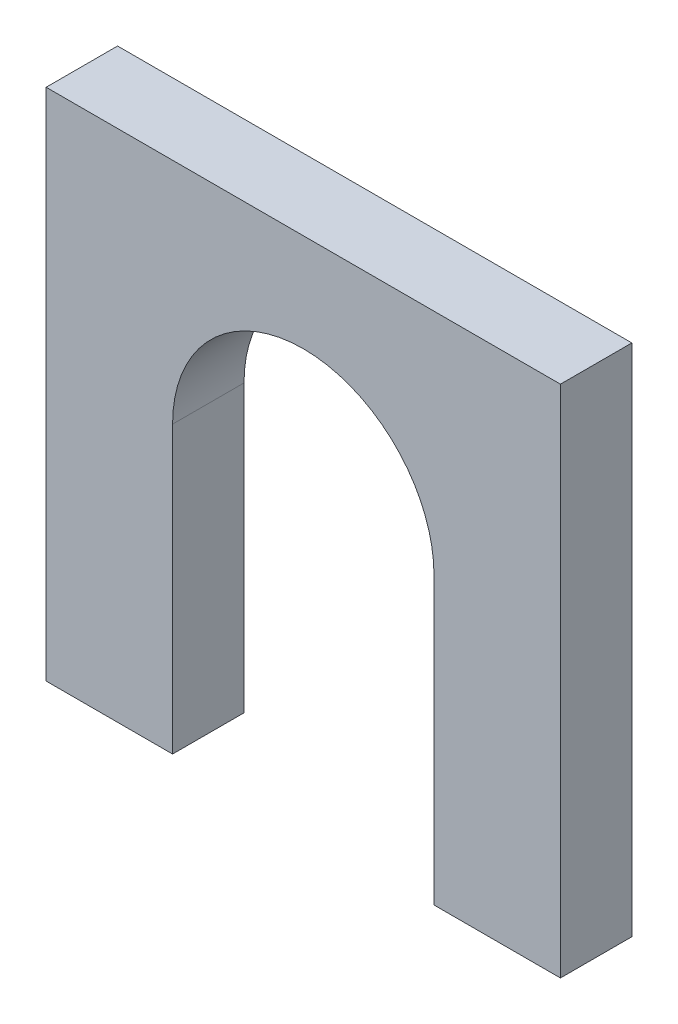
from build123d import *

# Parameters (mm, degrees)
BOSS_EXTRUDE1_DEPTH = 6.35


with BuildPart() as part:
    # Sketch1 → Boss-Extrude1 (new body)
    with BuildSketch(Plane.XY):
        with BuildLine():
            Line((34.4805, 0), (45.72, 0))
            Line((45.72, 0), (45.72, 45.72))
            Line((45.72, 45.72), (0, 45.72))
            Line((0, 45.72), (0, 0))
            Line((0, 0), (11.2395, 0))
            Line((11.2395, 0), (11.2395, 25.4))
            ThreePointArc((11.2395, 25.4), (22.86, 37.0205), (34.4805, 25.4))
            Line((34.4805, 25.4), (34.4805, 0))
        make_face()
    extrude(amount=BOSS_EXTRUDE1_DEPTH)


solid = part.part
